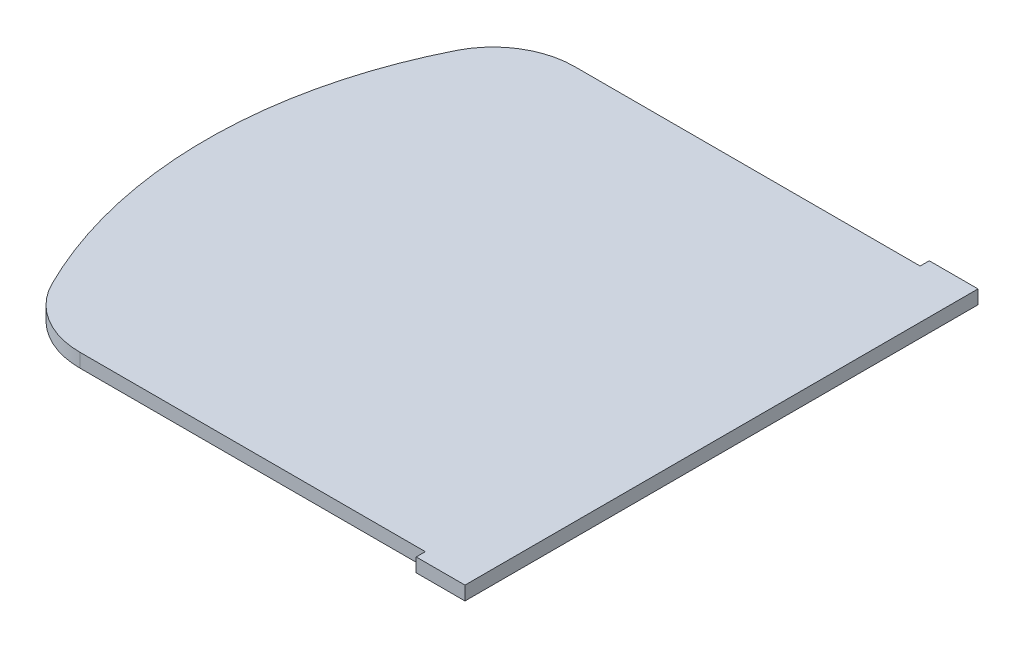
from build123d import *

# Parameters (mm, degrees)
BOSS_EXTRUDE1_DEPTH = 6.5


with BuildPart() as part:
    # Sketch1 → Boss-Extrude1 (new body, symmetric)
    with BuildSketch(Plane(origin=(0, 0, 0), x_dir=(1, 0, 0), z_dir=(0, 1, 0))):
        with BuildLine():
            Line((0, -242), (0, 242))
            Line((0, 242), (-46, 242))
            Line((-46, 242), (-46, 233.387339641))
            Line((-46, 233.387339641), (-372, 233.387339641))
            ThreePointArc((-372, 233.387339641), (-412.448780149, 221.907536408), (-440.836676218, 190.891136639))
            ThreePointArc((-440.836676218, 190.891136639), (-486, 0), (-440.836676218, -190.891136639))
            ThreePointArc((-440.836676218, -190.891136639), (-412.448780149, -221.907536408), (-372, -233.387339641))
            Line((-372, -233.387339641), (-46, -233.387339641))
            Line((-46, -233.387339641), (-46, -242))
            Line((-46, -242), (0, -242))
        make_face()
    extrude(amount=BOSS_EXTRUDE1_DEPTH, both=True)


solid = part.part
